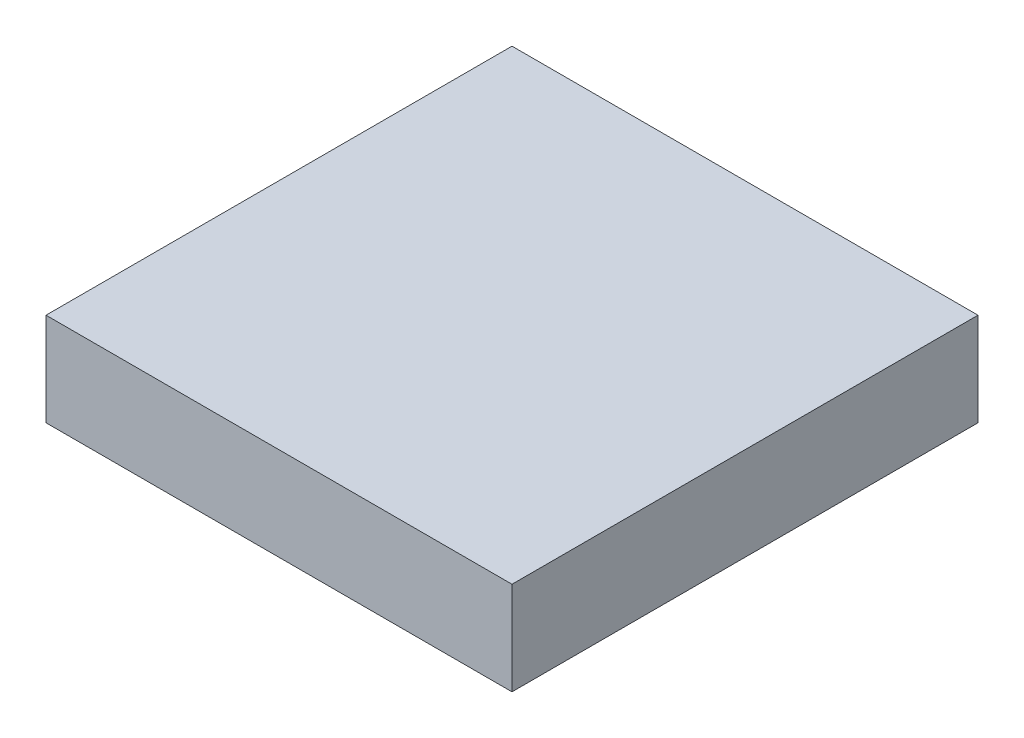
from build123d import *

# Parameters (mm, degrees)
SKETCH1_W           = 2
SKETCH1_H           = 2
BOSS_EXTRUDE1_DEPTH = 0.4


with BuildPart() as part:
    # Sketch1 → Boss-Extrude1 (new body)
    with BuildSketch(Plane(origin=(0, 0, 0), x_dir=(1, 0, 0), z_dir=(0, 1, 0))):
        Rectangle(SKETCH1_W, SKETCH1_H)
    extrude(amount=BOSS_EXTRUDE1_DEPTH)


solid = part.part
